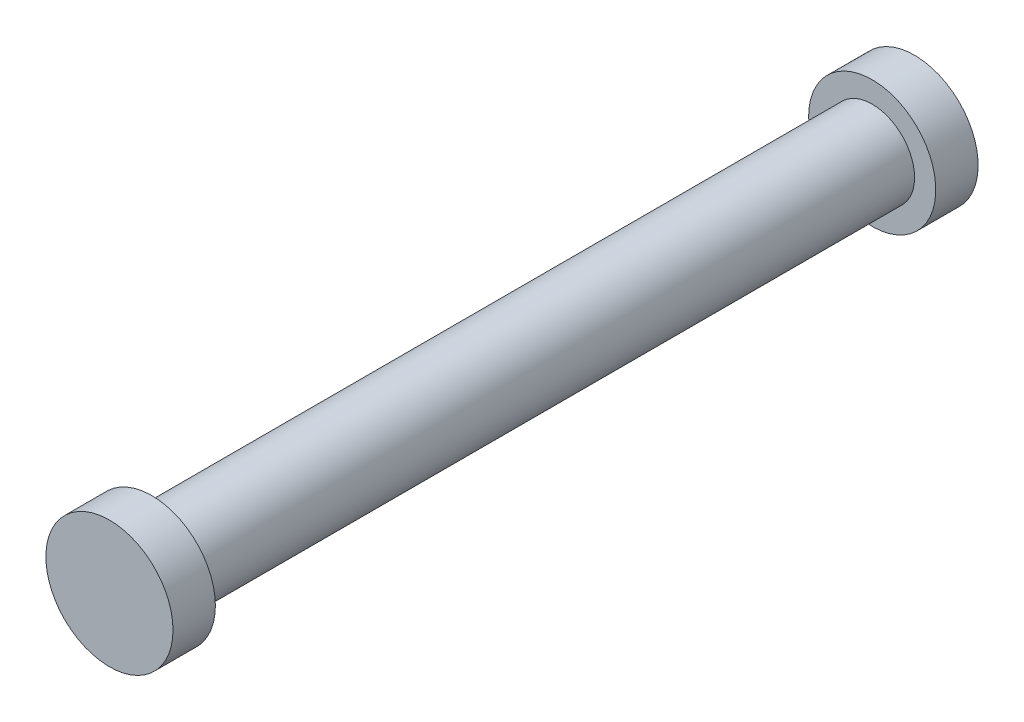
from build123d import *

# Parameters (mm, degrees)
SKETCH2_R           = 2
BOSS_EXTRUDE1_DEPTH = 34
SKETCH3_R           = 3
BOSS_EXTRUDE2_DEPTH = 2
SKETCH4_R           = 3
BOSS_EXTRUDE3_DEPTH = 2


with BuildPart() as part:
    # Sketch2 → Boss-Extrude1 (new body)
    with BuildSketch(Plane.XY):
        Circle(SKETCH2_R)
    extrude(amount=BOSS_EXTRUDE1_DEPTH)

    # Sketch3 → Boss-Extrude2 (add)
    with BuildSketch(Plane.XY.offset(34)):
        Circle(SKETCH3_R)
    extrude(amount=BOSS_EXTRUDE2_DEPTH)

    # Sketch4 → Boss-Extrude3 (add)
    with BuildSketch(Plane(origin=(0, 0, 0), x_dir=(-1, 0, 0), z_dir=(0, 0, -1))):
        Circle(SKETCH4_R)
    extrude(amount=BOSS_EXTRUDE3_DEPTH)


solid = part.part
